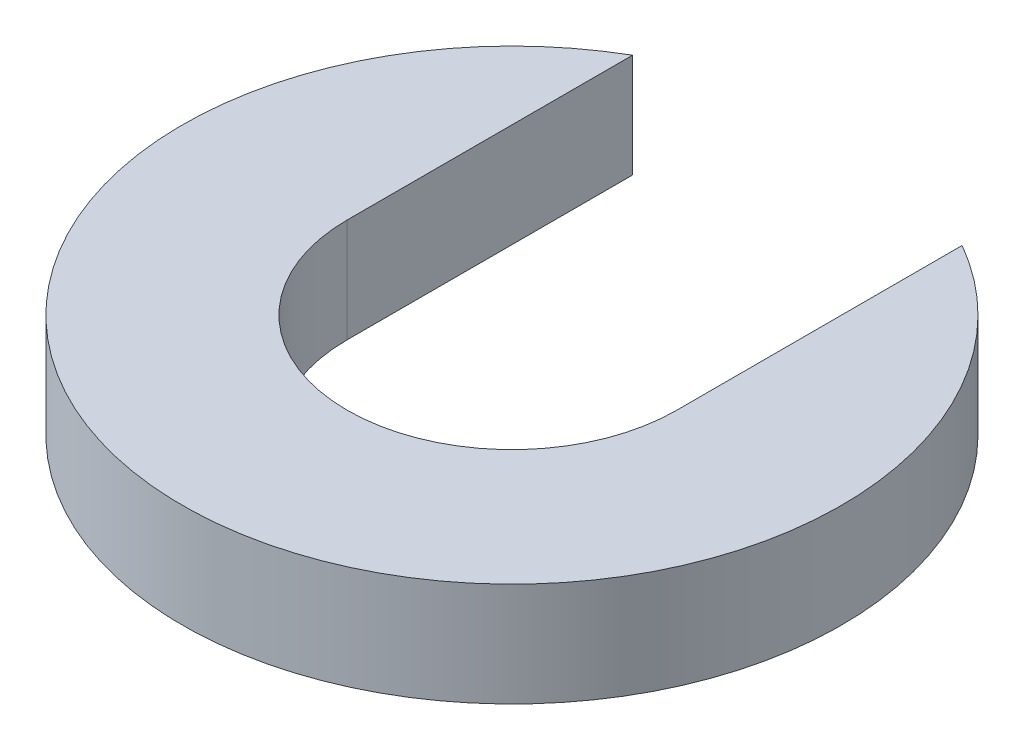
from build123d import *

# Parameters (mm, degrees)
BOSS_EXTRUDE1_DEPTH = 3


with BuildPart() as part:
    # Sketch1 → Boss-Extrude1 (new body)
    with BuildSketch(Plane(origin=(0, 0, 0), x_dir=(1, 0, 0), z_dir=(0, 1, 0))):
        with BuildLine():
            ThreePointArc((4.7625, 0), (0, -4.7625), (-4.7625, 0))
            Line((-4.7625, 0), (-4.7625, 8.248891971))
            ThreePointArc((-4.7625, 8.248891971), (-4.7625, -8.248891971), (9.525, 0))
            ThreePointArc((9.525, 0), (8.248891971, 4.7625), (4.7625, 8.248891971))
            Line((4.7625, 8.248891971), (4.7625, 0))
        make_face()
    extrude(amount=BOSS_EXTRUDE1_DEPTH)


solid = part.part
